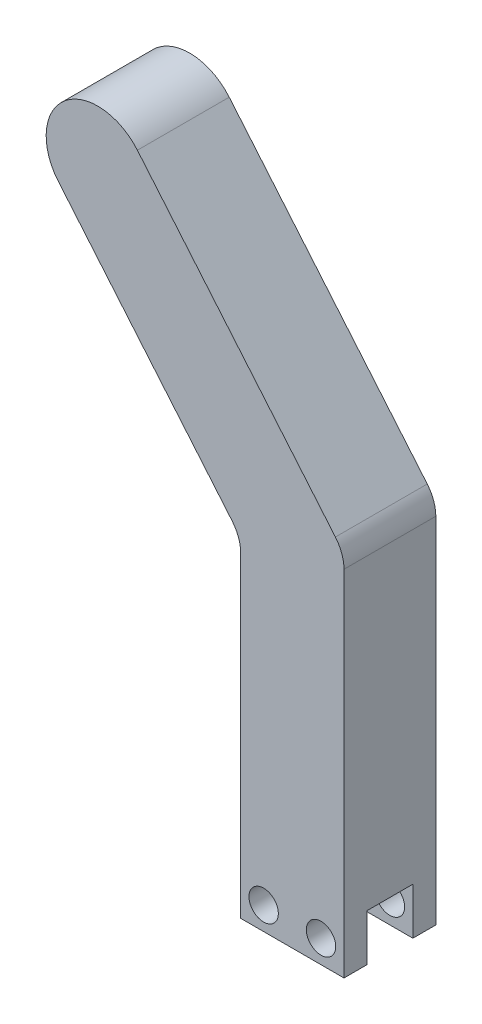
from build123d import *

# Parameters (mm, degrees)
SKETCH4_R           = 2.032
BOSS_EXTRUDE1_DEPTH = 12.7
SKETCH5_W           = 6.35
SKETCH5_H           = 6.47192
CUT_EXTRUDE1_DEPTH  = 15.2875
FILLET1_R           = 5.08


with BuildPart() as part:
    # Sketch4 → Boss-Extrude1 (new body)
    with BuildSketch(Plane.XY):
        with BuildLine():
            Line((0, -6.35), (-14.2875, -6.35))
            Line((-14.2875, -6.35), (-14.2875, 0))
            Line((-14.2875, 0), (-14.2875, 39.249775278))
            Line((-14.2875, 39.249775278), (-39.516769232, 69.316847523))
            ThreePointArc((-39.516769232, 69.316847523), (-38.636253228, 79.3811915), (-28.571909251, 78.500675497))
            Line((-28.571909251, 78.500675497), (0, 44.45))
            Line((0, 44.45), (0, 0))
            Line((0, 0), (0, -6.35))
        make_face()
        with Locations((-11.1125, -3.175)):
            Circle(SKETCH4_R, mode=Mode.SUBTRACT)
        with Locations((-3.175, -3.175)):
            Circle(SKETCH4_R, mode=Mode.SUBTRACT)
    extrude(amount=BOSS_EXTRUDE1_DEPTH)

    # Sketch5 → Cut-Extrude1 (cut, through all)
    with BuildSketch(Plane.ZY.offset(14.2875)):
        with Locations((6.35, -3.11404)):
            Rectangle(SKETCH5_W, SKETCH5_H)
    extrude(amount=-CUT_EXTRUDE1_DEPTH, mode=Mode.SUBTRACT)

    # Fillet1
    fillet1_edges = [part.edges().sort_by_distance(p)[0] for p in [
        (0, 44.45, 6.35),
        (-14.2875, 39.249775278, 6.35),
    ]]
    fillet(fillet1_edges, radius=FILLET1_R)


solid = part.part
